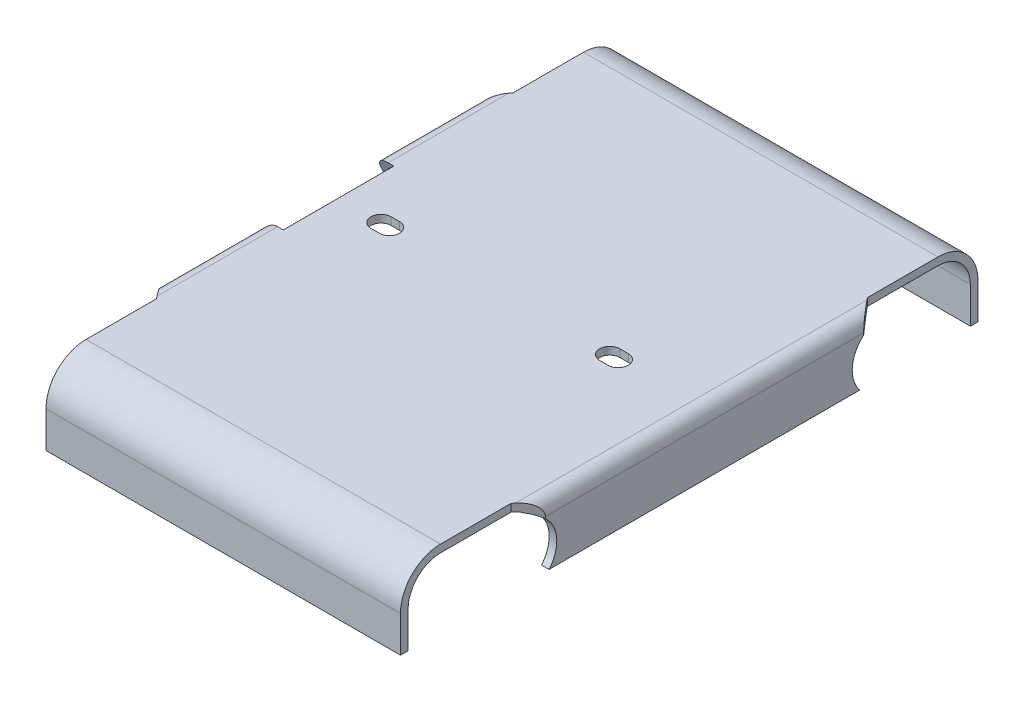
from build123d import *

# Parameters (mm, degrees)
ESQUISSE1_W                  = 101
ESQUISSE1_H                  = 151.5
EXTRUSION1_DEPTH             = 20
CONG_2_R                     = 10.5
CONG_3_R                     = 3.5
COQUE1_T                     = -2
ENL_V_MAT_EXTRU_4_DEPTH      = 21
ENL_V_MAT_EXTRU_1_DEPTH      = 51.5
ENL_V_MAT_EXTRU_1_DEPTH_BACK = 51.5
ENL_V_MAT_EXTRU_2_DEPTH      = 5
ENL_V_MAT_EXTRU_5_DEPTH      = 21


with BuildPart() as part:
    # Esquisse1 → Extrusion1 (new body)
    with BuildSketch(Plane(origin=(0, 0, 0), x_dir=(1, 0, 0), z_dir=(0, 1, 0))):
        Rectangle(ESQUISSE1_W, ESQUISSE1_H)
    extrude(amount=-EXTRUSION1_DEPTH)

    # Congé2
    cong_2_edges = [part.edges().sort_by_distance(p)[0] for p in [
        (0, 0, -75.75),
        (0, 0, 75.75),
    ]]
    fillet(cong_2_edges, radius=CONG_2_R)

    # Congé3
    cong_3_edges = [part.edges().sort_by_distance(p)[0] for p in [
        (-50.5, 0, 0),
        (50.5, 0, 0),
        (-50.5, -3.075378798, 72.674621202),
        (-50.5, -3.075378798, -72.674621202),
        (50.5, -3.075378798, 72.674621202),
        (50.5, -3.075378798, -72.674621202),
        (-50.5, -15.25, -75.75),
        (50.5, -15.25, -75.75),
        (50.5, -15.25, 75.75),
        (-50.5, -15.25, 75.75),
    ]]
    fillet(cong_3_edges, radius=CONG_3_R)

    # Coque1
    coque1_openings = [part.faces().sort_by_distance(p)[0] for p in [
        (0, -20, 0),
    ]]
    offset(amount=COQUE1_T, openings=coque1_openings, kind=Kind.INTERSECTION)

    # Esquisse5 → Enlèv. mat.-Extru.4 (cut, through all)
    with BuildSketch(Plane(origin=(0, 0, 0), x_dir=(-1, 0, 0), z_dir=(0, 1, 0))):
        Polygon((-46.5, -75.75), (-50.5, -75.75), (-50.5, -41.75), (-46.5, -46.75), align=None)
        Polygon((-46.5, 46.75), (-50.5, 41.75), (-50.5, 75.75), (-46.5, 75.75), align=None)
        Polygon((46.5, 75.75), (50.5, 75.75), (50.5, 41.75), (46.5, 46.75), align=None)
        Polygon((46.5, -46.75), (50.5, -41.75), (50.5, -75.75), (46.5, -75.75), align=None)
    extrude(amount=-ENL_V_MAT_EXTRU_4_DEPTH, mode=Mode.SUBTRACT)

    # Esquisse2 → Enlèv. mat.-Extru.1 (cut, two sides)
    with BuildSketch(Plane(origin=(0, 0, 0), x_dir=(0, 0, -1), z_dir=(1, 0, 0))) as enl_v_mat_extru_1_sk:
        with BuildLine():
            Line((-73.75, -10.5), (-73.75, -20))
            Line((-73.75, -20), (73.75, -20))
            Line((73.75, -20), (73.75, -10.5))
            ThreePointArc((73.75, -10.5), (71.26040764, -4.48959236), (65.25, -2))
            Line((65.25, -2), (47.25, -2))
            ThreePointArc((47.25, -2), (39.53637569, -6.929285786), (40.769259302, -16))
            Line((40.769259302, -16), (-40.769259302, -16))
            ThreePointArc((-40.769259302, -16), (-39.53637569, -6.929285786), (-47.25, -2))
            Line((-47.25, -2), (-65.25, -2))
            ThreePointArc((-65.25, -2), (-71.26040764, -4.48959236), (-73.75, -10.5))
        make_face()
    extrude(amount=ENL_V_MAT_EXTRU_1_DEPTH, mode=Mode.SUBTRACT)
    extrude(enl_v_mat_extru_1_sk.sketch, amount=-ENL_V_MAT_EXTRU_1_DEPTH_BACK, mode=Mode.SUBTRACT)

    # Esquisse3 → Enlèv. mat.-Extru.2 (cut)
    with BuildSketch(Plane.ZY.offset(50.5)):
        Polygon((-17.75, -16), (-17.75, -7), (-14.5, 0), (14.5, 0), (17.75, -7), (17.75, -16), align=None)
    extrude(amount=-ENL_V_MAT_EXTRU_2_DEPTH, mode=Mode.SUBTRACT)

    # Esquisse6 → Enlèv. mat.-Extru.5 (cut, through all)
    with BuildSketch(Plane(origin=(0, 0, 0), x_dir=(-1, 0, 0), z_dir=(0, 1, 0))):
        with BuildLine():
            Line((-25.65, 2.65), (-27.85, 2.65))
            ThreePointArc((-27.85, 2.65), (-30.5, 0), (-27.85, -2.65))
            Line((-27.85, -2.65), (-25.65, -2.65))
            ThreePointArc((-25.65, -2.65), (-23, 0), (-25.65, 2.65))
        make_face()
        with BuildLine():
            Line((32.15, -2.65), (34.35, -2.65))
            ThreePointArc((34.35, -2.65), (37, 0), (34.35, 2.65))
            Line((34.35, 2.65), (32.15, 2.65))
            ThreePointArc((32.15, 2.65), (29.5, 0), (32.15, -2.65))
        make_face()
    extrude(amount=-ENL_V_MAT_EXTRU_5_DEPTH, mode=Mode.SUBTRACT)


solid = part.part
